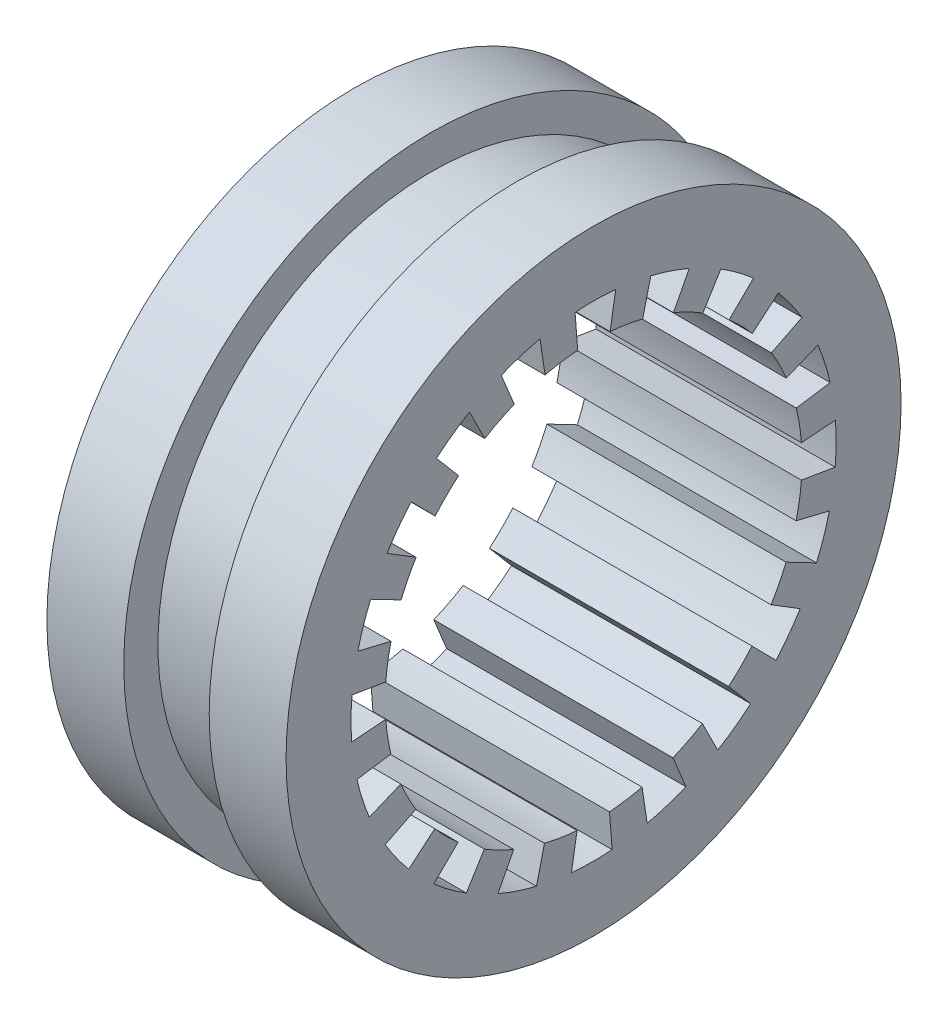
from build123d import *

# Parameters (mm, degrees)
SKETCH1_R           = 90
SKETCH1_R_2         = 61
BOSS_EXTRUDE1_DEPTH = 35
SKETCH2_R           = 59
CUT_EXTRUDE1_DEPTH  = 71
CIRPATTERN1_COUNT   = 20
CUT_EXTRUDE2_START  = -35
SKETCH3_R           = 90
SKETCH3_R_2         = 80
CUT_EXTRUDE2_DEPTH  = 12.5


with BuildPart() as part:
    # Sketch1 → Boss-Extrude1 (new body, symmetric)
    with BuildSketch(Plane(origin=(0, 0, 0), x_dir=(0, 0, -1), z_dir=(1, 0, 0))):
        Circle(SKETCH1_R)
        Circle(SKETCH1_R_2, mode=Mode.SUBTRACT)
    extrude(amount=BOSS_EXTRUDE1_DEPTH, both=True)

    # Sketch2 → Cut-Extrude1 (cut, through all)
    with BuildSketch(Plane(origin=(35, 0, 0), x_dir=(0, 0, -1), z_dir=(1, 0, 0))):
        Circle(SKETCH2_R)
        with BuildLine():
            Line((0, 51.395835648), (-4.5, 58.828139525))
            Line((-4.5, 58.828139525), (-5.415254237, 70.793184852))
            ThreePointArc((-5.415254237, 70.793184852), (0.535268123, 70.997982281), (6.48202623, 70.703488853))
            Line((6.48202623, 70.703488853), (4.5, 58.828139525))
            Line((4.5, 58.828139525), (0, 51.395835648))
        make_face()
    cut_extrude1 = extrude(amount=-CUT_EXTRUDE1_DEPTH, mode=Mode.SUBTRACT)

    # CirPattern1: Cut-Extrude1 ×20 about axis
    cirpattern1_axis = Axis((0, 0, 0), (1, 0, 0))
    for i in range(1, CIRPATTERN1_COUNT):
        add(cut_extrude1.rotate(cirpattern1_axis, i * 360 / CIRPATTERN1_COUNT), mode=Mode.SUBTRACT)

    # Sketch3 → Cut-Extrude2 (cut, symmetric)
    with BuildSketch(Plane(origin=(35, 0, 0), x_dir=(0, 0, -1), z_dir=(1, 0, 0)).offset(CUT_EXTRUDE2_START)):
        Circle(SKETCH3_R)
        Circle(SKETCH3_R_2, mode=Mode.SUBTRACT)
    extrude(amount=CUT_EXTRUDE2_DEPTH, both=True, mode=Mode.SUBTRACT)


solid = part.part
